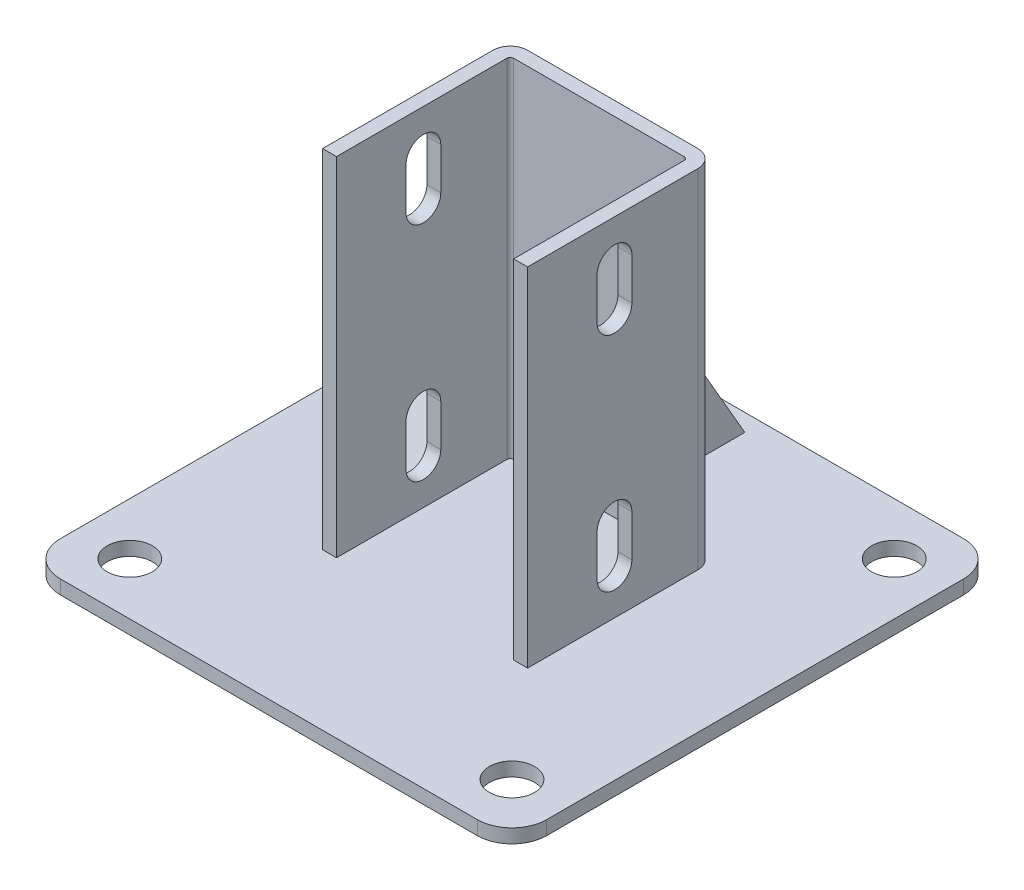
from build123d import *

# Parameters (mm, degrees)
SKETCH_2_W          = 140
SKETCH_2_H          = 140
EXTRUDE_1_DEPTH     = 4
EXTRUDE_1_2_DEPTH   = 100
EXTRUDE_2_DEPTH     = 2
CUT_EXTRUDE_1_DEPTH = 100.5
SKETCH_6_R          = 6.5
CUT_EXTRUDE_2_DEPTH = 5
FILLET_1_R          = 10


with BuildPart() as part:
    # Эскиз2 → Extrude 1 (new body)
    with BuildSketch(Plane(origin=(0, 0, 0), x_dir=(1, 0, 0), z_dir=(0, 1, 0))):
        Rectangle(SKETCH_2_W, SKETCH_2_H)
    extrude(amount=EXTRUDE_1_DEPTH)

    # Эскиз3 → Extrude 1 2 (add)
    with BuildSketch(Plane(origin=(0, 4, 0), x_dir=(1, 0, 0), z_dir=(0, 1, 0))):
        with BuildLine():
            Line((-25.5, -25), (-25.5, 24))
            ThreePointArc((-25.5, 24), (-25.207106781, 24.707106781), (-24.5, 25))
            Line((-24.5, 25), (24.5, 25))
            ThreePointArc((24.5, 25), (25.207106781, 24.707106781), (25.5, 24))
            Line((25.5, 24), (25.5, -25))
            Line((25.5, -25), (29.5, -25))
            Line((29.5, -25), (29.5, 24))
            ThreePointArc((29.5, 24), (28.035533906, 27.535533906), (24.5, 29))
            Line((24.5, 29), (-24.5, 29))
            ThreePointArc((-24.5, 29), (-28.035533906, 27.535533906), (-29.5, 24))
            Line((-29.5, 24), (-29.5, -25))
            Line((-29.5, -25), (-25.5, -25))
        make_face()
    extrude(amount=EXTRUDE_1_2_DEPTH)

    # Эскиз4 → Бобышка-Вытянуть2 (add, symmetric)
    with BuildSketch(Plane(origin=(0, 0, 0), x_dir=(0, 0, -1), z_dir=(1, 0, 0))):
        Polygon((29, 66.353829072), (65, 4), (29, 4), align=None)
    extrude(amount=EXTRUDE_2_DEPTH, both=True)

    # Эскиз5 → Вырез-Вытянуть1 (cut, through all)
    with BuildSketch(Plane(origin=(29.5, 0, 0), x_dir=(0, 0, -1), z_dir=(1, 0, 0))):
        with BuildLine():
            Line((5, 92), (5, 80))
            ThreePointArc((5, 80), (0, 75), (-5, 80))
            Line((-5, 80), (-5, 92))
            ThreePointArc((-5, 92), (0, 97), (5, 92))
        make_face()
        with BuildLine():
            Line((5, 28), (5, 16))
            ThreePointArc((5, 16), (0, 11), (-5, 16))
            Line((-5, 16), (-5, 28))
            ThreePointArc((-5, 28), (0, 33), (5, 28))
        make_face()
    extrude(amount=-CUT_EXTRUDE_1_DEPTH, mode=Mode.SUBTRACT)

    # Эскиз6 → Вырез-Вытянуть2 (cut, through all)
    with BuildSketch(Plane(origin=(0, 4, 0), x_dir=(1, 0, 0), z_dir=(0, 1, 0))):
        with Locations(Location((-55, 55, 0), (0, 0, 270))):  # turned: the seam where the file's is
            Circle(SKETCH_6_R)
        with Locations(Location((-55, -55, 0), (0, 0, 270))):  # turned: the seam where the file's is
            Circle(SKETCH_6_R)
        with Locations(Location((55, 55, 0), (0, 0, 270))):  # turned: the seam where the file's is
            Circle(SKETCH_6_R)
        with Locations(Location((55, -55, 0), (0, 0, 270))):  # turned: the seam where the file's is
            Circle(SKETCH_6_R)
    extrude(amount=-CUT_EXTRUDE_2_DEPTH, mode=Mode.SUBTRACT)

    # Скругление1
    fillet_1_edges = [part.edges().sort_by_distance(p)[0] for p in [
        (70, 2, 70),
        (-70, 2, 70),
        (-70, 2, -70),
        (70, 2, -70),
    ]]
    fillet(fillet_1_edges, radius=FILLET_1_R)


solid = part.part
